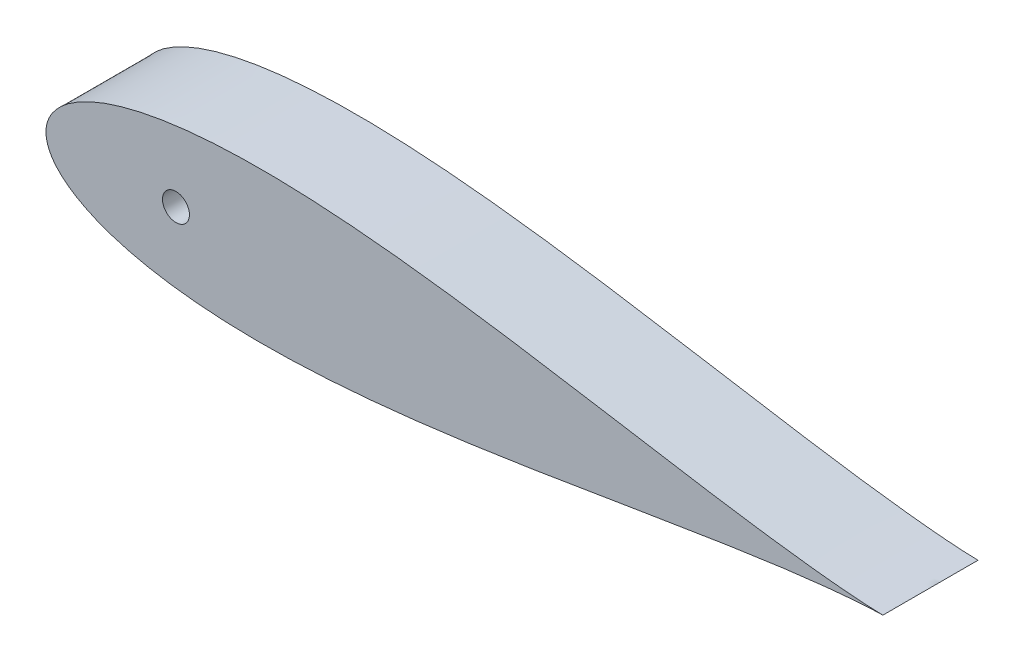
from build123d import *

# Parameters (mm, degrees)
BOSS_EXTRUDE1_DEPTH = 76.2
SKETCH3_R           = 10.795
CUT_EXTRUDE2_DEPTH  = 76.2


with BuildPart() as part:
    # Sketch1 → Boss-Extrude1 (new body)
    with BuildSketch(Plane.XY):
        with BuildLine():
            Line((643.966787522, 0), (643.599082689, 0))
            Line((643.599082689, 0), (643.599082689, -1.016))
            ThreePointArc((643.599082689, -1.016), (643.872033494, -0.540245973), (643.966787522, 0))
        make_face()
        with BuildLine():
            Line((643.599082689, -1.016), (643.599082689, 0))
            Line((643.599082689, 0), (641.567082689, 0))
            ThreePointArc((641.567082689, 0), (642.269121423, -1.135922533), (643.599082689, -1.016))
        make_face()
        with BuildLine():
            Line((641.567082689, 0), (643.599082689, 0))
            Line((643.599082689, 0), (643.966787522, 0))
            ThreePointArc((643.966787522, 0), (643.547407924, 1.075012082), (642.510849283, 1.582039112))
            add(Edge.make_bspline(
                [(642.510849283, 1.582039112), (641.993392355, 1.625070631), (638.093728429, 1.953546407), (630.413817462, 2.663385493), (619.014124193, 3.849253664), (606.374988512, 5.304428983), (592.543922516, 7.037634907), (577.585454095, 9.050636147), (561.564270734, 11.338919625), (544.549749946, 13.890665375), (526.614143658, 16.687720753), (507.832591566, 19.705111663), (488.282710288, 22.911672601), (468.044367735, 26.27043606), (447.199424328, 29.739007432), (425.831595832, 33.270324121), (404.02631566, 36.813220545), (381.870662856, 40.313266856), (359.453314895, 43.713502532), (336.86454415, 46.955447457), (314.196207315, 49.979843895), (291.541767704, 52.727712704), (268.996310773, 55.141201012), (246.65655865, 57.164603829), (224.620860897, 58.745176641), (202.989192599, 59.8341217), (181.863132616, 60.387506142), (161.345829027, 60.366961324), (141.542033828, 59.739895824), (122.558104573, 58.481758104), (104.502313427, 56.574303932), (87.485018636, 54.008935199), (71.619696083, 50.784752003), (57.023709725, 46.912543066), (43.82045433, 42.41500246), (32.141645239, 37.332204029), (22.129107375, 31.731455339), (13.932423524, 25.726412106), (7.689616489, 19.513207632), (3.463136343, 13.420354421), (1.106333228, 7.923389435), (0.154611582, 3.513796615), (0, 1.007496172), (0, 0)],
                knots=[0.020157042, 0.020157042, 0.020157042, 0.020157042, 0.021270888, 0.028552555, 0.036780684, 0.045920102, 0.055931764, 0.066772884, 0.07839713, 0.090754827, 0.103793165, 0.117456432, 0.131686226, 0.146421738, 0.161599998, 0.177156133, 0.193023668, 0.209134786, 0.225420633, 0.241811602, 0.258237647, 0.274628557, 0.290914287, 0.307025229, 0.322892517, 0.338448342, 0.353626207, 0.368361232, 0.382590428, 0.396252961, 0.409290412, 0.42164701, 0.433269881, 0.444109249, 0.45411864, 0.463255055, 0.471479114, 0.478755289, 0.485052318, 0.490344026, 0.494609833, 0.497833231, 0.5, 0.5, 0.5, 0.5], degree=3))
            Line((0, 0), (27.94, 0))
            ThreePointArc((27.94, 0), (40.64, 12.7), (53.34, 0))
            Line((53.34, 0), (93.345, 0))
            ThreePointArc((93.345, 0), (104.14, 10.795), (114.935, 0))
            Line((114.935, 0), (460.660965279, 0))
            Line((460.660965279, 0), (473.360965279, 0))
            Line((473.360965279, 0), (641.567082689, 0))
        make_face()
        with BuildLine():
            ThreePointArc((642.510849283, -1.582039112), (643.111845681, -1.408373102), (643.599082689, -1.016))
            ThreePointArc((643.599082689, -1.016), (642.269121423, -1.135922533), (641.567082689, 0))
            Line((641.567082689, 0), (473.360965279, 0))
            Line((473.360965279, 0), (460.660965279, 0))
            Line((460.660965279, 0), (114.935, 0))
            ThreePointArc((114.935, 0), (104.14, -10.795), (93.345, 0))
            Line((93.345, 0), (53.34, 0))
            ThreePointArc((53.34, 0), (40.64, -12.7), (27.94, 0))
            Line((27.94, 0), (0, 0))
            add(Edge.make_bspline(
                [(0, 0), (0, -1.007496172), (0.154611582, -3.513796615), (1.106333228, -7.923389435), (3.463136343, -13.420354421), (7.689616489, -19.513207632), (13.932423524, -25.726412106), (22.129107375, -31.731455339), (32.141645239, -37.332204029), (43.82045433, -42.41500246), (57.023709725, -46.912543066), (71.619696083, -50.784752003), (87.485018636, -54.008935199), (104.502313427, -56.574303932), (122.558104573, -58.481758104), (141.542033828, -59.739895824), (161.345829027, -60.366961324), (181.863132616, -60.387506142), (202.989192599, -59.8341217), (224.620860897, -58.745176641), (246.65655865, -57.164603829), (268.996310773, -55.141201012), (291.541767704, -52.727712704), (314.196207315, -49.979843895), (336.86454415, -46.955447457), (359.453314895, -43.713502532), (381.870662856, -40.313266856), (404.02631566, -36.813220545), (425.831595832, -33.270324121), (447.199424328, -29.739007432), (468.044367735, -26.27043606), (488.282710288, -22.911672601), (507.832591566, -19.705111663), (526.614143658, -16.687720753), (544.549749946, -13.890665375), (561.564270734, -11.338919625), (577.585454095, -9.050636147), (592.543922516, -7.037634907), (606.374988512, -5.304428983), (619.014124193, -3.849253664), (630.413817462, -2.663385493), (638.093728429, -1.953546407), (641.993392355, -1.625070631), (642.510849283, -1.582039112)],
                knots=[0.5, 0.5, 0.5, 0.5, 0.502166769, 0.505390167, 0.509655974, 0.514947682, 0.521244711, 0.528520886, 0.536744945, 0.54588136, 0.555890751, 0.566730119, 0.57835299, 0.590709588, 0.603747039, 0.617409572, 0.631638768, 0.646373793, 0.661551658, 0.677107483, 0.692974771, 0.709085713, 0.725371443, 0.741762353, 0.758188398, 0.774579367, 0.790865214, 0.806976332, 0.822843867, 0.838400002, 0.853578262, 0.868313774, 0.882543568, 0.896206835, 0.909245173, 0.92160287, 0.933227116, 0.944068236, 0.954079898, 0.963219316, 0.971447445, 0.978729112, 0.979842958, 0.979842958, 0.979842958, 0.979842958], degree=3))
        make_face()
        with BuildLine():
            ThreePointArc((643.966787522, 0), (643.872033494, -0.540245973), (643.599082689, -1.016))
            ThreePointArc((643.599082689, -1.016), (643.111845681, -1.408373102), (642.510849283, -1.582039112))
            add(Edge.make_bspline(
                [(642.510849283, -1.582039112), (644.922074617, -1.381522545), (649.798936594, -1.000308437), (656.504964311, -0.543558383), (662.850933168, -0.234427605), (666.344759683, -0.054696708), (670.56, -0.015678595), (670.56, 0)],
                knots=[0.979842958, 0.979842958, 0.979842958, 0.979842958, 0.985033212, 0.990332793, 0.994605218, 0.997832222, 1, 1, 1, 1], degree=3))
            add(Edge.make_bspline(
                [(670.56, 0), (670.56, 0.015678595), (666.344759683, 0.054696708), (662.850933168, 0.234427605), (656.504964311, 0.543558383), (649.798936594, 1.000308437), (644.922074617, 1.381522545), (642.510849283, 1.582039112)],
                knots=[0, 0, 0, 0, 0.002167778, 0.005394782, 0.009667207, 0.014966788, 0.020157042, 0.020157042, 0.020157042, 0.020157042], degree=3))
            ThreePointArc((642.510849283, 1.582039112), (643.547407924, 1.075012082), (643.966787522, 0))
        make_face()
        with BuildLine():
            ThreePointArc((53.34, 0), (40.64, 12.7), (27.94, 0))
            Line((27.94, 0), (53.34, 0))
        make_face()
        with BuildLine():
            Line((53.34, 0), (27.94, 0))
            ThreePointArc((27.94, 0), (40.64, -12.7), (53.34, 0))
        make_face()
        with BuildLine():
            ThreePointArc((93.345, 0), (104.14, -10.795), (114.935, 0))
            Line((114.935, 0), (93.345, 0))
        make_face()
        with BuildLine():
            Line((93.345, 0), (114.935, 0))
            ThreePointArc((114.935, 0), (104.14, 10.795), (93.345, 0))
        make_face()
    extrude(amount=BOSS_EXTRUDE1_DEPTH)

    # Sketch3 → Cut-Extrude2 (cut)
    with BuildSketch(Plane.XY.offset(76.2)):
        with Locations((104.139232412, 0)):
            Circle(SKETCH3_R)
    extrude(amount=-CUT_EXTRUDE2_DEPTH, mode=Mode.SUBTRACT)


solid = part.part
